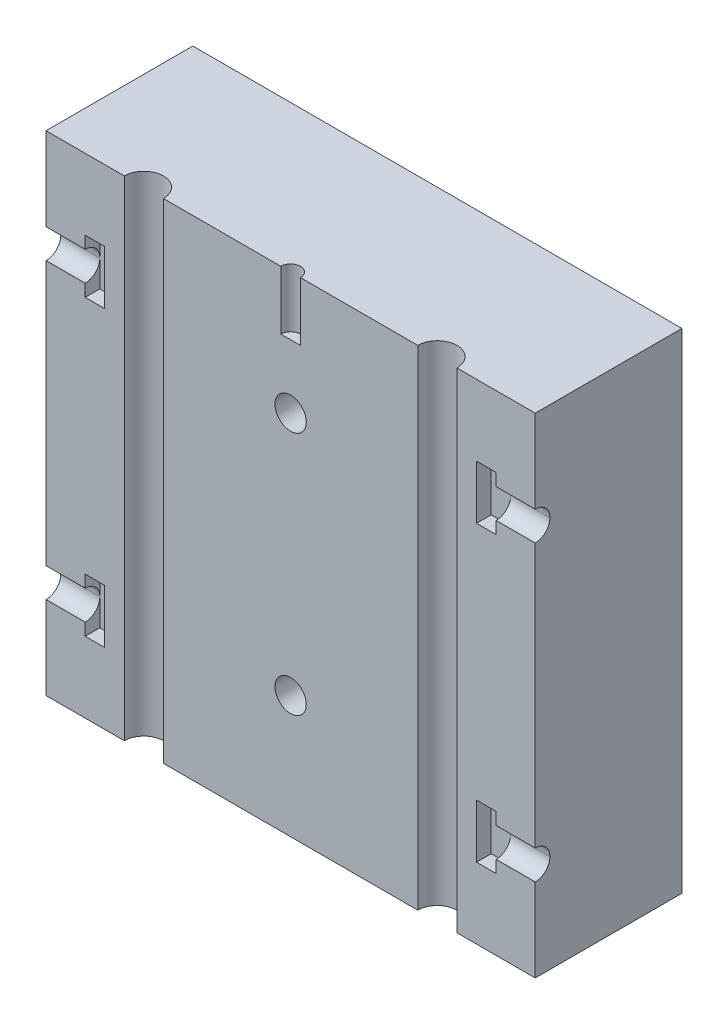
from build123d import *

# Parameters (mm, degrees)
ESQUISSE1_W             = 50
ESQUISSE1_H             = 50
ESQUISSE1_R             = 1.6
EXTRUSION1_DEPTH        = 15
ESQUISSE2_R             = 2
ENL_V_MAT_EXTRU_1_DEPTH = 51
ENL_V_MAT_EXTRU_3_DEPTH = 1.5
CONG_1_R                = 1.49
CONG_2_R                = 1.49
ESQUISSE4_R             = 1
ENL_V_MAT_EXTRU_4_DEPTH = 6


with BuildPart() as part:
    # Esquisse1 → Extrusion1 (new body)
    with BuildSketch(Plane.XY):
        with Locations((25, 25)):
            Rectangle(ESQUISSE1_W, ESQUISSE1_H)
        with Locations((25, 37.5)):
            Circle(ESQUISSE1_R, mode=Mode.SUBTRACT)
        with Locations(Location((25, 12.5, 0), (0, 0, 180))):  # turned: the seam where the file's is
            Circle(ESQUISSE1_R, mode=Mode.SUBTRACT)
    extrude(amount=EXTRUSION1_DEPTH)

    # Esquisse2 → Enlèv. mat.-Extru.1 (cut, through all)
    with BuildSketch(Plane(origin=(0, 50, 0), x_dir=(-1, 0, 0), z_dir=(0, 1, 0))):
        with Locations((-10, 15)):
            Circle(ESQUISSE2_R)
        with Locations((-40, 15)):
            Circle(ESQUISSE2_R)
    extrude(amount=-ENL_V_MAT_EXTRU_1_DEPTH, mode=Mode.SUBTRACT)

    # Esquisse3 → Enlèv. mat.-Extru.3 (cut)
    with BuildSketch(Plane.XY.offset(15)):
        Polygon((-1.134972747, 11.5), (4, 11.5), (4, 12.75), (6, 12.75), (6, 7.25), (4, 7.25), (4, 8.5), (-1.134972747, 8.5), align=None)
        Polygon((-1.134972747, 38.5), (-1.134972747, 41.5), (4, 41.5), (4, 42.75), (6, 42.75), (6, 37.25), (4, 37.25), (4, 38.5), align=None)
        Polygon((46, 42.75), (44, 42.75), (44, 37.25), (46, 37.25), (46, 38.5), (51.134972747, 38.5), (51.134972747, 41.5), (46, 41.5), align=None)
        Polygon((46, 12.75), (44, 12.75), (44, 7.25), (46, 7.25), (46, 8.5), (51.134972747, 8.5), (51.134972747, 11.5), (46, 11.5), align=None)
    extrude(amount=-ENL_V_MAT_EXTRU_3_DEPTH, mode=Mode.SUBTRACT)

    # Congé1
    cong_1_edges = [part.edges().sort_by_distance(p)[0] for p in [
        (2, 11.5, 13.5),
    ]]
    fillet(cong_1_edges, radius=CONG_1_R)

    # Congé2
    cong_2_edges = [part.edges().sort_by_distance(p)[0] for p in [
        (48, 11.5, 13.5),
        (48, 8.5, 13.5),
        (2, 8.5, 13.5),
        (2, 38.5, 13.5),
        (2, 41.5, 13.5),
        (48, 41.5, 13.5),
        (48, 38.5, 13.5),
    ]]
    fillet(cong_2_edges, radius=CONG_2_R)

    # Esquisse4 → Enlèv. mat.-Extru.4 (cut)
    with BuildSketch(Plane(origin=(0, 50, 0), x_dir=(-1, 0, 0), z_dir=(0, 1, 0))):
        with Locations((-25, 15)):
            Circle(ESQUISSE4_R)
    extrude(amount=-ENL_V_MAT_EXTRU_4_DEPTH, mode=Mode.SUBTRACT)


solid = part.part
